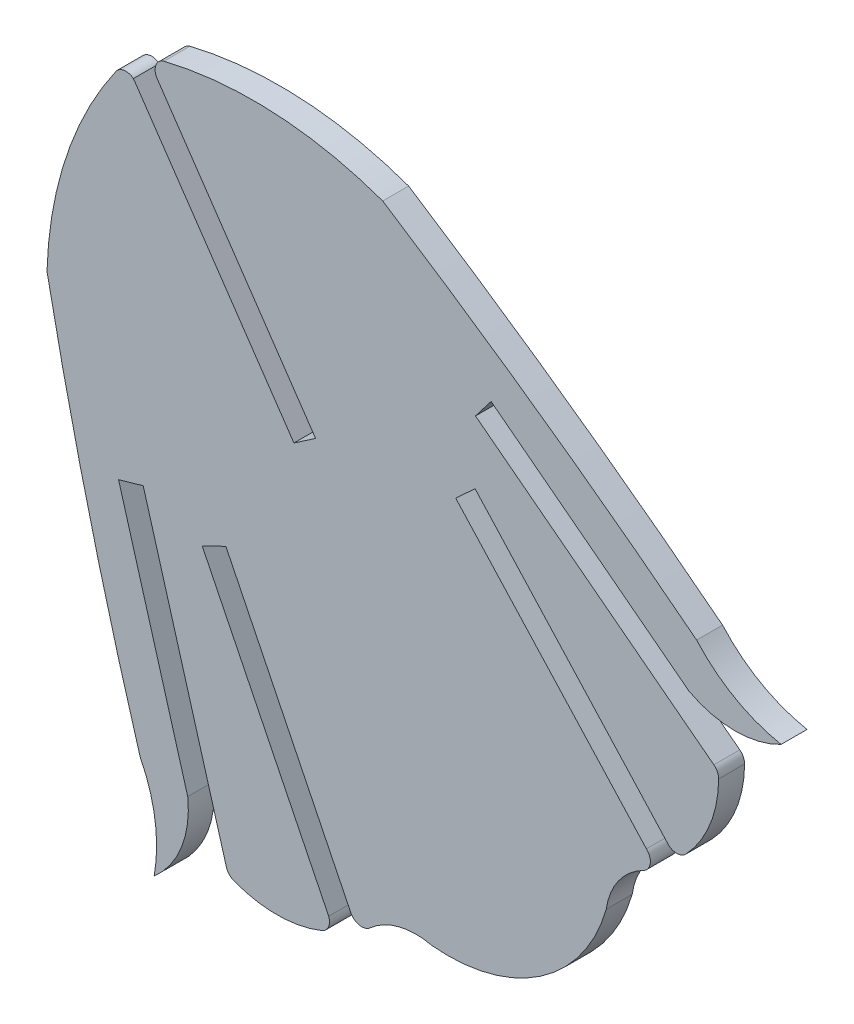
from build123d import *

# Parameters (mm, degrees)
BOSS_EXTRUDE1_DEPTH = 1.524


with BuildPart() as part:
    # Sketch1 → Boss-Extrude1 (new body)
    with BuildSketch(Plane.XY):
        with BuildLine():
            Line((189.777315793, 495.507175139), (191.224820624, 495.924635056))
            Line((191.224820624, 495.924635056), (196.119223328, 478.946810438))
            ThreePointArc((196.119223328, 478.946810438), (196.281524624, 478.657917117), (196.555651913, 478.471757801))
            ThreePointArc((196.555651913, 478.471757801), (199.147753156, 478.005869728), (201.730327533, 478.521960937))
            ThreePointArc((201.730327533, 478.521960937), (202.122931571, 478.905936562), (202.132531096, 479.455011294))
            Line((202.132531096, 479.455011294), (194.696378786, 494.588452914))
            Line((194.696378786, 494.588452914), (196.085953758, 495.269690236))
            Line((196.085953758, 495.269690236), (203.4004902, 480.349637502))
            ThreePointArc((203.4004902, 480.349637502), (203.905544625, 479.909328052), (204.555334637, 480.072806873))
            ThreePointArc((204.555334637, 480.072806873), (206.275233543, 480.984321258), (208.221715491, 480.995218384))
            ThreePointArc((208.221715491, 480.995218384), (214.599649086, 482.633856482), (218.454712821, 487.972550644))
            ThreePointArc((218.454712821, 487.972550644), (219.175843378, 489.780555467), (220.652597524, 491.048667416))
            ThreePointArc((220.652597524, 491.048667416), (221.042127495, 491.593845171), (220.816722181, 492.224832356))
            Line((220.816722181, 492.224832356), (209.599367356, 504.483762477))
            Line((209.599367356, 504.483762477), (210.741099412, 505.528487706))
            Line((210.741099412, 505.528487706), (222.112676203, 493.07840105))
            ThreePointArc((222.112676203, 493.07840105), (222.627317714, 492.886778176), (223.128167093, 493.112000535))
            ThreePointArc((223.128167093, 493.112000535), (224.551927983, 495.327614554), (225.065041618, 497.910782173))
            ThreePointArc((225.065041618, 497.910782173), (224.99187518, 498.233965919), (224.782226996, 498.490575936))
            Line((224.782226996, 498.490575936), (210.765290937, 509.248234144))
            Line((210.765290937, 509.248234144), (211.682631799, 510.443235718))
            Line((211.682631799, 510.443235718), (223.328487329, 501.504872294))
            ThreePointArc((223.328487329, 501.504872294), (226.03151825, 500.838137649), (228.73454917, 501.504872294))
            ThreePointArc((228.73454917, 501.504872294), (226.018822109, 502.512994153), (223.768735069, 504.337436936))
            ThreePointArc((223.768735069, 504.337436936), (214.697892634, 511.126772614), (205.306886221, 517.465878226))
            ThreePointArc((205.306886221, 517.465878226), (198.926193665, 518.755629479), (192.444429164, 518.152782293))
            ThreePointArc((192.444429164, 518.152782293), (191.977714673, 517.727994557), (192.022339489, 517.098490258))
            Line((192.022339489, 517.098490258), (201.361944543, 503.400969482))
            Line((201.361944543, 503.400969482), (200.088434986, 502.532398479))
            Line((200.088434986, 502.532398479), (190.651660212, 516.372267313))
            ThreePointArc((190.651660212, 516.372267313), (190.110139611, 516.517556306), (189.627566711, 516.232114806))
            ThreePointArc((189.627566711, 516.232114806), (186.698797428, 510.418423529), (185.568771317, 504.007515889))
            ThreePointArc((185.568771317, 504.007515889), (188.039633015, 492.949934603), (191.046560533, 482.025940447))
            ThreePointArc((191.046560533, 482.025940447), (191.923055704, 479.264919011), (191.869552453, 476.368607468))
            ThreePointArc((191.869552453, 476.368607468), (193.477546562, 478.641329665), (193.844210588, 481.401124718))
            Line((193.844210588, 481.401124718), (189.777315793, 495.507175139))
        make_face()
    extrude(amount=BOSS_EXTRUDE1_DEPTH)


solid = part.part
